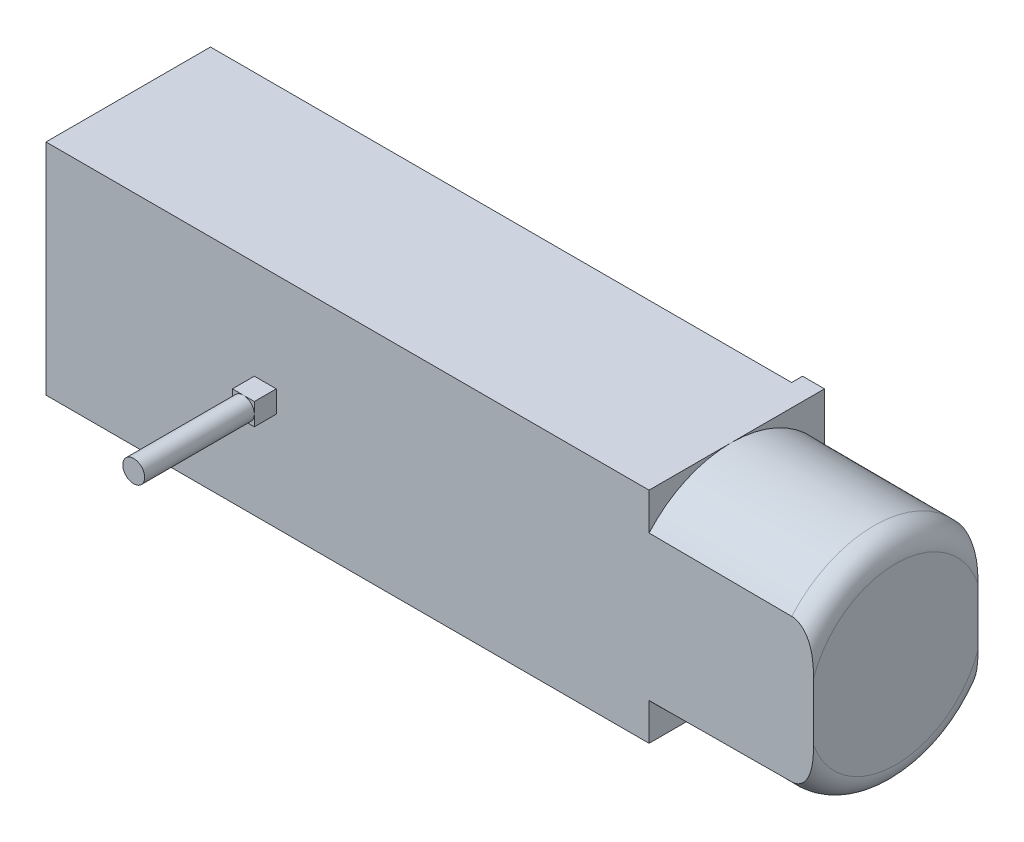
from build123d import *

# Parameters (mm, degrees)
SKETCH_1_W          = 15
SKETCH_1_H          = 20
EXTRUDE_1_DEPTH     = 55
SKETCH_3_W          = 2
SKETCH_3_H          = 6
EXTRUDE_2_DEPTH     = 1
SKETCH_4_W          = 2
SKETCH_4_H          = 2
EXTRUDE_3_DEPTH     = 2
SKETCH_5_W          = 6.633447251
SKETCH_5_H          = 20.27238771
SKETCH_5_W_2        = 12.16711561
SKETCH_5_H_2        = 23.052373823
CUT_EXTRUDE_1_DEPTH = 24
SKETCH_6_R          = 1
EXTRUDE_4_DEPTH     = 10


with BuildPart() as part:
    # 草图1 → 凸台-拉伸1 (new body)
    with BuildSketch(Plane(origin=(0, 0, 0), x_dir=(0, 0, -1), z_dir=(1, 0, 0))):
        Rectangle(SKETCH_1_W, SKETCH_1_H)
    extrude(amount=EXTRUDE_1_DEPTH)

    # 草图2 → 旋转1 (revolve)
    with BuildSketch(Plane.XY):
        with BuildLine():
            Line((55, 0), (70, 0))
            Line((70, 0), (70, 7.947586675))
            ThreePointArc((70, 7.947586675), (69.417060699, 9.358947358), (68.008061024, 9.94757043))
            Line((68.008061024, 9.94757043), (55, 10))
            Line((55, 10), (55, 0))
        make_face()
    revolve(axis=Axis((55, 0, 0), (1, 0, 0)))

    # 草图3 → 凸台-拉伸2 (add)
    with BuildSketch(Plane(origin=(0, 0, -7.5), x_dir=(-1, 0, 0), z_dir=(0, 0, -1))):
        with Locations((-54, 7)):
            Rectangle(SKETCH_3_W, SKETCH_3_H)
        with Locations((-54, -7)):
            Rectangle(SKETCH_3_W, SKETCH_3_H)
    extrude(amount=EXTRUDE_2_DEPTH)

    # 草图4 → 凸台-拉伸3 (add)
    with BuildSketch(Plane.XY.offset(7.5)):
        with Locations((20, 0)):
            Rectangle(SKETCH_4_W, SKETCH_4_H)
    extrude(amount=EXTRUDE_3_DEPTH)

    # 草图5 → 切除-拉伸1 (cut)
    with BuildSketch(Plane.ZY.offset(-55)):
        with Locations((-10.816723626, -0.136193855)):
            Rectangle(SKETCH_5_W, SKETCH_5_H)
        with Locations((13.583557805, -1.526186911)):
            Rectangle(SKETCH_5_W_2, SKETCH_5_H_2)
    extrude(amount=-CUT_EXTRUDE_1_DEPTH, mode=Mode.SUBTRACT)

    # 草图6 → 凸台-拉伸4 (add)
    with BuildSketch(Plane.XY.offset(9.5)):
        with Locations((20, 0)):
            Circle(SKETCH_6_R)
    extrude(amount=EXTRUDE_4_DEPTH)


solid = part.part
